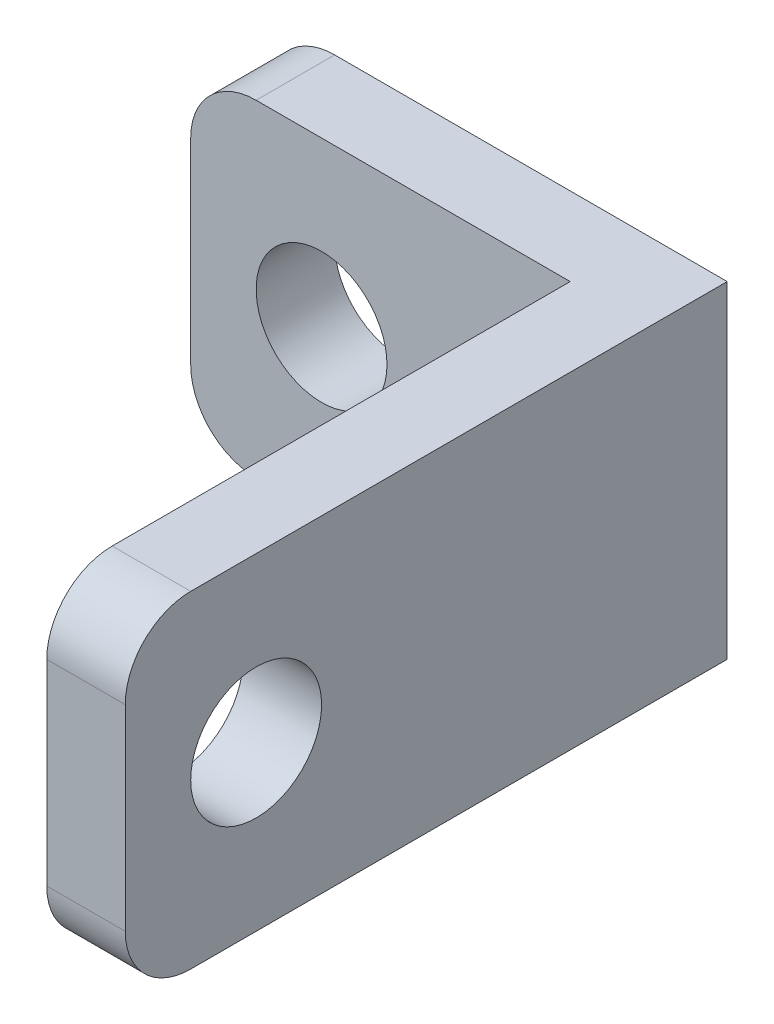
from build123d import *

# Parameters (mm, degrees)
SKETCH_1_R          = 1
EXTRUDE_1_DEPTH     = 1.2
SKETCH_2_W          = 1.2
SKETCH_2_H          = 5
EXTRUDE_2_DEPTH     = 8
FILLET_1_R          = 1
SKETCH_4_R          = 1
CUT_EXTRUDE_1_DEPTH = 2


with BuildPart() as part:
    # 草图1 → 凸台-拉伸1 (new body)
    with BuildSketch(Plane.XY):
        with BuildLine():
            Line((1, 0), (7, 0))
            Line((7, 0), (7, 5))
            Line((7, 5), (1, 5))
            ThreePointArc((1, 5), (0.292893219, 4.707106781), (0, 4))
            Line((0, 4), (0, 1))
            ThreePointArc((0, 1), (0.292893219, 0.292893219), (1, 0))
        make_face()
        with Locations((2, 2.5)):
            Circle(SKETCH_1_R, mode=Mode.SUBTRACT)
    extrude(amount=EXTRUDE_1_DEPTH)

    # 草图2 → 凸台-拉伸2 (add)
    with BuildSketch(Plane(origin=(0, 0, 1.2), x_dir=(-1, 0, 0), z_dir=(0, 0, -1))):
        with Locations((-6.4, 2.5)):
            Rectangle(SKETCH_2_W, SKETCH_2_H)
    extrude(amount=-EXTRUDE_2_DEPTH)

    # 圆角1
    fillet_1_edges = [part.edges().sort_by_distance(p)[0] for p in [
        (6.4, 0, 9.2),
        (6.4, 5, 9.2),
    ]]
    fillet(fillet_1_edges, radius=FILLET_1_R)

    # 草图4 → 切除-拉伸1 (cut)
    with BuildSketch(Plane.ZY.offset(-5.8)):
        with Locations((7.2, 2.5)):
            Circle(SKETCH_4_R)
    extrude(amount=-CUT_EXTRUDE_1_DEPTH, mode=Mode.SUBTRACT)


solid = part.part
